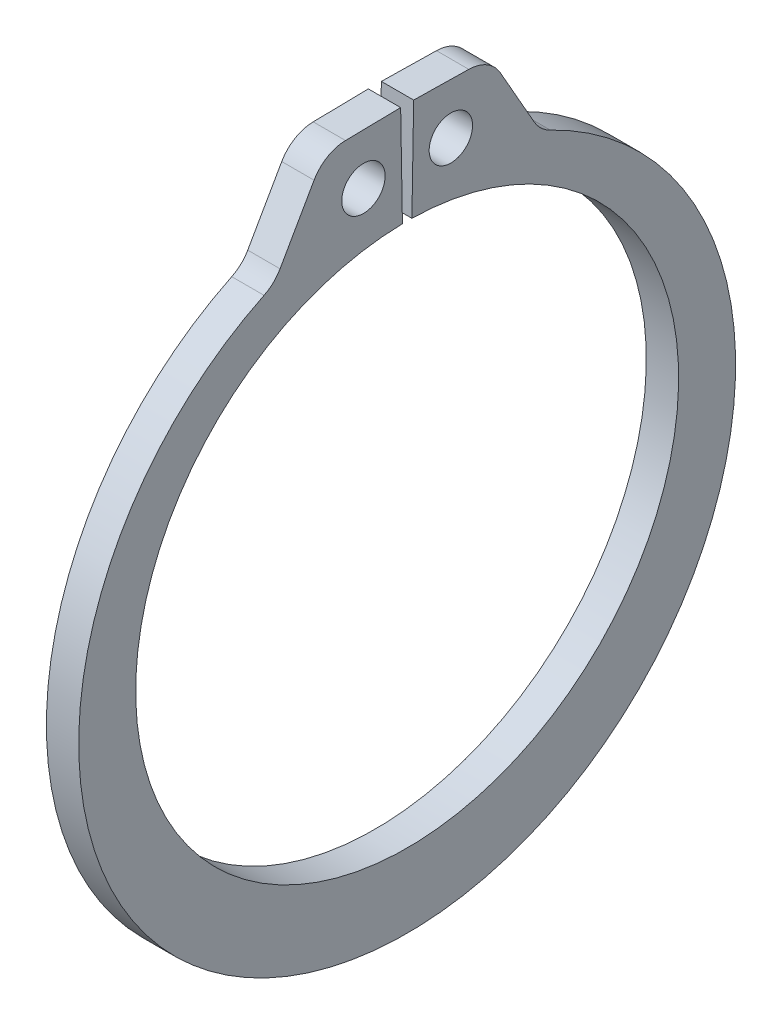
from build123d import *

# Parameters (mm, degrees)
SKETCH1_R      = 0.5969
EXTRUDE1_DEPTH = 0.4445
FILLET1_R      = 1.016


with BuildPart() as part:
    # Sketch1 → Extrude1 (new body, symmetric)
    with BuildSketch(Plane(origin=(0, 0, 0), x_dir=(0, 0, -1), z_dir=(1, 0, 0))):
        with BuildLine():
            Line((-0.13032759, 7.466462648), (-0.179089614, 10.260037109))
            Line((-0.179089614, 10.260037109), (-2.274270459, 10.223465591))
            Line((-2.274270459, 10.223465591), (-3.65683248, 7.795512079))
            ThreePointArc((-3.65683248, 7.795512079), (0, -9.4996), (3.65683248, 7.795512079))
            Line((3.65683248, 7.795512079), (2.274270459, 10.223465591))
            Line((2.274270459, 10.223465591), (0.179089614, 10.260037109))
            Line((0.179089614, 10.260037109), (0.13032759, 7.466462648))
            ThreePointArc((0.13032759, 7.466462648), (0, -7.4676), (-0.13032759, 7.466462648))
        make_face()
        with Locations((-1.202299025, 8.84496412)):
            Circle(SKETCH1_R, mode=Mode.SUBTRACT)
        with Locations((1.202299025, 8.84496412)):
            Circle(SKETCH1_R, mode=Mode.SUBTRACT)
    extrude(amount=EXTRUDE1_DEPTH, both=True)

    # Fillet1
    fillet1_edges = [part.edges().sort_by_distance(p)[0] for p in [
        (0, 10.223465591, -2.274270459),
        (0, 7.795512079, -3.65683248),
        (0, 7.795512079, 3.65683248),
        (0, 10.223465591, 2.274270459),
    ]]
    fillet(fillet1_edges, radius=FILLET1_R)


solid = part.part
